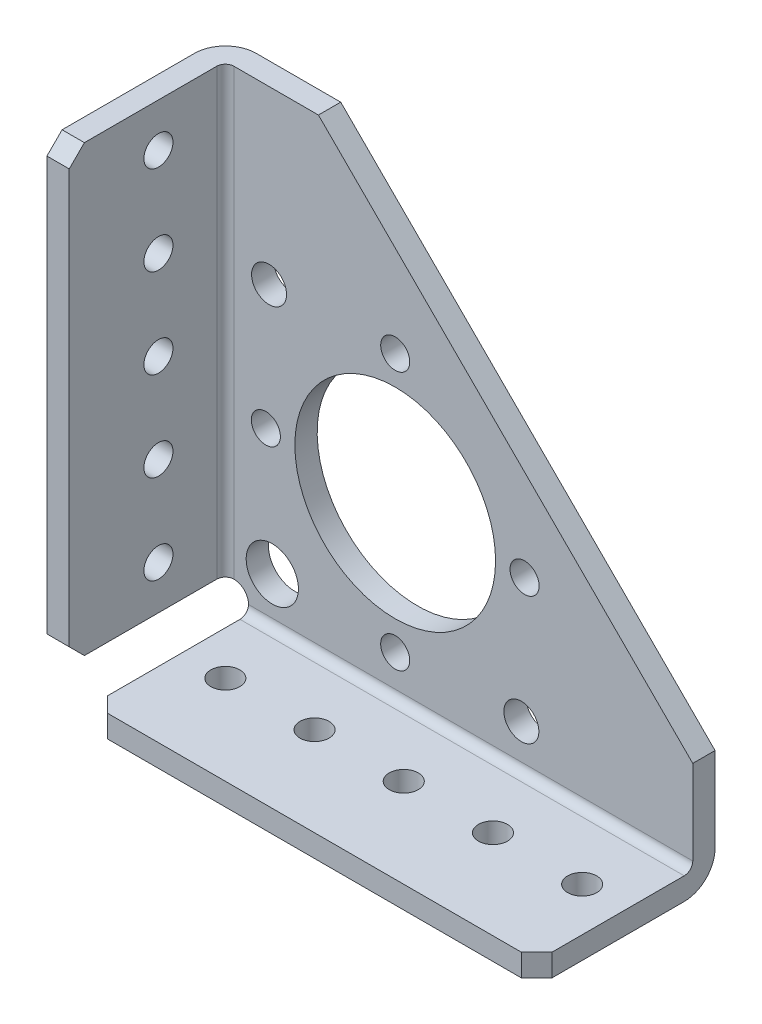
from build123d import *

# Parameters (mm, degrees)
BOSS_EXTRUDE1_DEPTH        = 3.175
SKETCH2_W                  = 6.477
SKETCH2_H                  = 6.477
CUT_EXTRUDE1_DEPTH         = 4.175
SKETCH3_W                  = 63.246
SKETCH3_H                  = 3.175
BOSS_EXTRUDE2_DEPTH        = 22.225
SKETCH4_W                  = 3.175
SKETCH4_H                  = 63.246
BOSS_EXTRUDE3_DEPTH        = 22.225
M6_5_CLEARANCE_HOLE1_D     = 7.4422
M6_5_CLEARANCE_HOLE1_DEPTH = 25.400025
M25_CLEARANCE_HOLE1_D      = 28.575
M25_CLEARANCE_HOLE1_DEPTH  = 25.400025
HOLE1_D                    = 4.9784
HOLE1_DEPTH                = 25.400025
M3_5_CLEARANCE_HOLE1_D     = 4.1402
M3_5_CLEARANCE_HOLE1_DEPTH = 25.400025
M3_5_CLEARANCE_HOLE2_D     = 4.1402
M3_5_CLEARANCE_HOLE2_DEPTH = 3.175
M3_5_CLEARANCE_HOLE3_D     = 4.1402
M3_5_CLEARANCE_HOLE3_DEPTH = 3.175
CHAMFER1_SIZE              = 2.159
FILLET1_R                  = 1.2192
FILLET2_R                  = 2.0701
FILLET3_R                  = 4.3942


with BuildPart() as part:
    # Sketch1 → Boss-Extrude1 (new body)
    with BuildSketch(Plane(origin=(0, 0, 0), x_dir=(-1, 0, 0), z_dir=(0, 0, -1))):
        Polygon((-69.723, 0), (0, 0), (0, 69.723), (-16.428128061, 69.723), (-69.723, 16.428128061), align=None)
    extrude(amount=-BOSS_EXTRUDE1_DEPTH)

    # Sketch2 → Cut-Extrude1 (cut, through all)
    with BuildSketch(Plane(origin=(0, 0, 0), x_dir=(-1, 0, 0), z_dir=(0, 0, -1))):
        with Locations((-3.2385, 3.2385)):
            Rectangle(SKETCH2_W, SKETCH2_H)
    extrude(amount=-CUT_EXTRUDE1_DEPTH, mode=Mode.SUBTRACT)

    # Sketch3 → Boss-Extrude2 (add)
    with BuildSketch(Plane.XY.offset(3.175)):
        with Locations((38.1, 1.5875)):
            Rectangle(SKETCH3_W, SKETCH3_H)
    extrude(amount=BOSS_EXTRUDE2_DEPTH)

    # Sketch4 → Boss-Extrude3 (add)
    with BuildSketch(Plane.XY.offset(3.175)):
        with Locations((1.5875, 38.1)):
            Rectangle(SKETCH4_W, SKETCH4_H)
    extrude(amount=BOSS_EXTRUDE3_DEPTH)

    # M6.5 Clearance Hole1
    with Locations(Plane(origin=(0, 0, 0), x_dir=(-1, 0, 0), z_dir=(0, 0, -1))):
        with Locations((-9.85939269, 9.85939269)):
            Hole(M6_5_CLEARANCE_HOLE1_D / 2, depth=M6_5_CLEARANCE_HOLE1_DEPTH)

    # M25 Clearance Hole1
    with Locations(Plane(origin=(0, 0, 0), x_dir=(-1, 0, 0), z_dir=(0, 0, -1))):
        with Locations((-27.360115818, 27.360115818)):
            Hole(M25_CLEARANCE_HOLE1_D / 2, depth=M25_CLEARANCE_HOLE1_DEPTH)

    # Hole1
    with Locations(Plane(origin=(0, 0, 0), x_dir=(-1, 0, 0), z_dir=(0, 0, -1))):
        with Locations((-9.399603576, 45.320628061), (-45.320628061, 9.399603576)):
            Hole(HOLE1_D / 2, depth=HOLE1_DEPTH)

    # M3.5 Clearance Hole1
    with Locations(Plane(origin=(0, 0, 0), x_dir=(-1, 0, 0), z_dir=(0, 0, -1))):
        with Locations((-45.775115818, 27.360115818), (-8.945115818, 27.360115818), (-27.360115818, 45.775115818), (-27.360115818, 8.945115818)):
            Hole(M3_5_CLEARANCE_HOLE1_D / 2, depth=M3_5_CLEARANCE_HOLE1_DEPTH)

    # M3.5 Clearance Hole2
    with Locations(Plane(origin=(3.175, 0, 0), x_dir=(0, 0, -1), z_dir=(1, 0, 0))):
        with Locations((-12.7, 63.5), (-12.7, 50.8), (-12.7, 38.1), (-12.7, 25.4), (-12.7, 12.7)):
            Hole(M3_5_CLEARANCE_HOLE2_D / 2, depth=M3_5_CLEARANCE_HOLE2_DEPTH)

    # M3.5 Clearance Hole3
    with Locations(Plane(origin=(0, 3.175, 0), x_dir=(1, 0, 0), z_dir=(0, 1, 0))):
        with Locations((63.5, -12.7), (50.8, -12.7), (38.1, -12.7), (25.4, -12.7), (12.7, -12.7)):
            Hole(M3_5_CLEARANCE_HOLE3_D / 2, depth=M3_5_CLEARANCE_HOLE3_DEPTH)

    # Chamfer1
    chamfer1_edges = [part.edges().sort_by_distance(p)[0] for p in [
        (1.5875, 6.477, 25.4),
        (1.5875, 69.723, 25.4),
        (6.477, 1.5875, 25.4),
        (69.723, 1.5875, 25.4),
    ]]
    chamfer(chamfer1_edges, length=CHAMFER1_SIZE)

    # Fillet1
    fillet1_edges = [part.edges().sort_by_distance(p)[0] for p in [
        (38.1, 3.175, 3.175),
        (3.175, 38.1, 3.175),
    ]]
    fillet(fillet1_edges, radius=FILLET1_R)

    # Fillet2
    fillet2_edges = [part.edges().sort_by_distance(p)[0] for p in [
        (6.477, 6.477, 1.5875),
    ]]
    fillet(fillet2_edges, radius=FILLET2_R)

    # Fillet3
    fillet3_edges = [part.edges().sort_by_distance(p)[0] for p in [
        (0, 38.1, 0),
        (38.1, 0, 0),
    ]]
    fillet(fillet3_edges, radius=FILLET3_R)


solid = part.part
